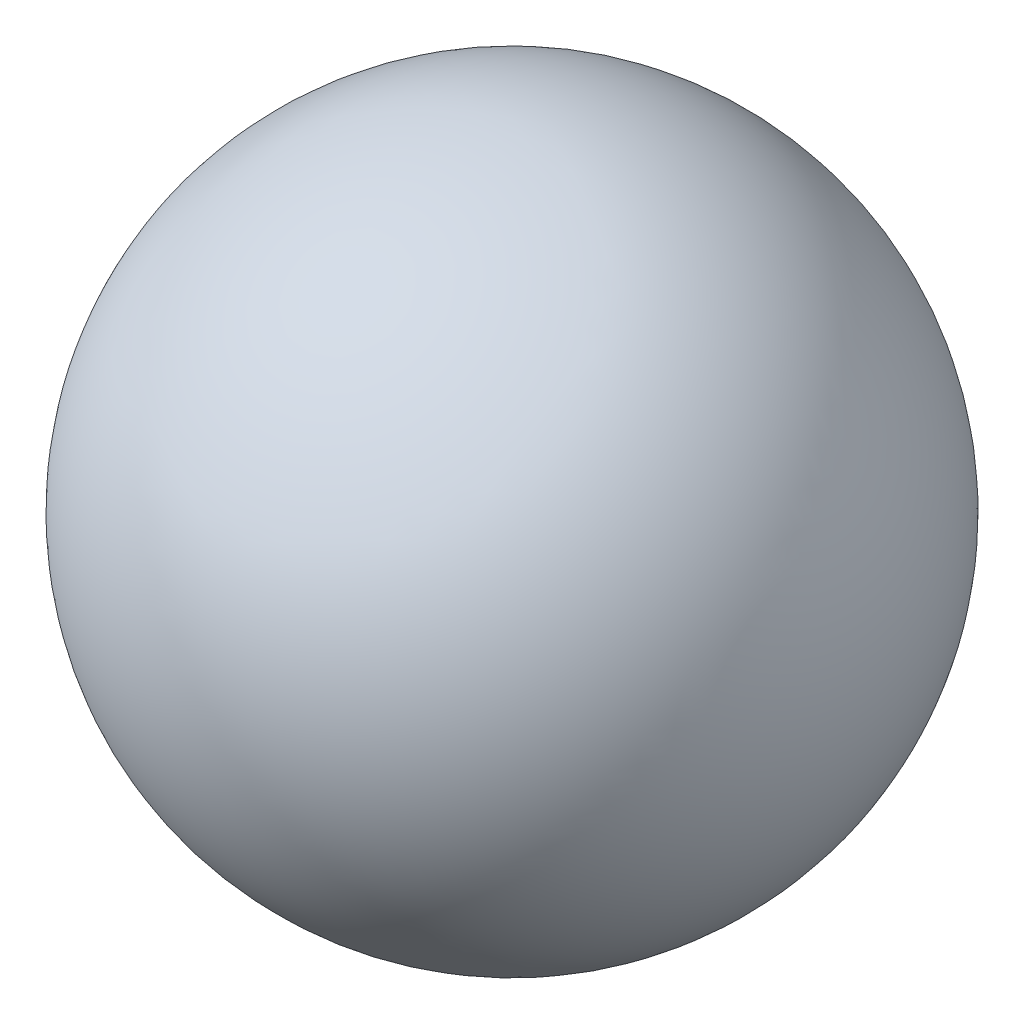
from build123d import *


with BuildPart() as part:
    # Sketch1 → Revolve1 (revolve)
    with BuildSketch(Plane(origin=(0, 0, 0), x_dir=(1, 0, 0), z_dir=(0, 1, 0))):
        with BuildLine():
            Line((-47.625, 0), (47.625, 0))
            ThreePointArc((47.625, 0), (0, -47.625), (-47.625, 0))
        make_face()
    revolve(axis=Axis((47.625, 0, 0), (1, 0, 0)))


solid = part.part
